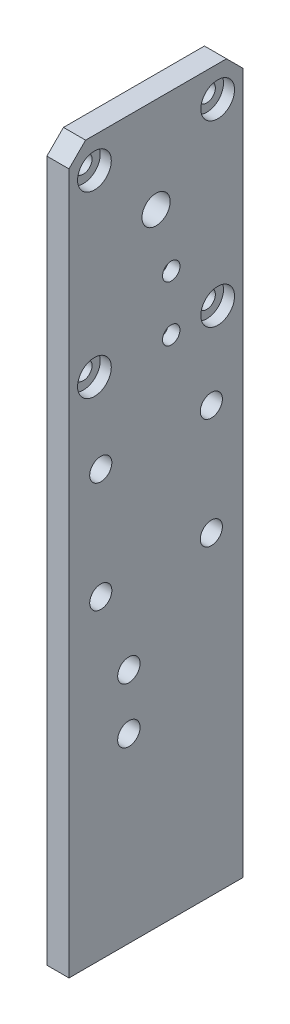
from build123d import *

# Parameters (mm, degrees)
CROQUIS1_W              = 31.5
CROQUIS1_H              = 126
SALIENTE_EXTRUIR1_DEPTH = 4
CROQUIS3_R              = 2
CORTAR_EXTRUIR2_DEPTH   = 5
CROQUIS8_R              = 2.55
CORTAR_EXTRUIR3_DEPTH   = 5
CROQUIS11_R             = 1.575
CORTAR_EXTRUIR8_DEPTH   = 5
CROQUIS15_R             = 1.575
CORTAR_EXTRUIR11_DEPTH  = 5
CHAFL_N2_SIZE           = 3
CROQUIS19_R             = 3.5
CORTAR_EXTRUIR13_DEPTH  = 1.9
CROQUIS20_R             = 3.05
CORTAR_EXTRUIR14_DEPTH  = 2
CROQUIS24_W             = 31.5
CROQUIS24_H             = 3.76
SALIENTE_EXTRUIR3_DEPTH = 4
CROQUIS25_R             = 2.025
CORTAR_EXTRUIR15_DEPTH  = 5


with BuildPart() as part:
    # Croquis1 → Saliente-Extruir1 (new body)
    with BuildSketch(Plane(origin=(0, 0, 0), x_dir=(0, 0, -1), z_dir=(1, 0, 0))):
        Rectangle(CROQUIS1_W, CROQUIS1_H)
    extrude(amount=SALIENTE_EXTRUIR1_DEPTH)

    # Croquis3 → Cortar-Extruir2 (cut, through all)
    with BuildSketch(Plane(origin=(4, 0, 0), x_dir=(0, 0, -1), z_dir=(1, 0, 0))):
        with Locations((-10, 10.1)):
            Circle(CROQUIS3_R)
        with Locations((10, 10.1)):
            Circle(CROQUIS3_R)
        with Locations((-10, -9.9)):
            Circle(CROQUIS3_R)
        with Locations((10, -9.9)):
            Circle(CROQUIS3_R)
    extrude(amount=-CORTAR_EXTRUIR2_DEPTH, mode=Mode.SUBTRACT)

    # Croquis8 → Cortar-Extruir3 (cut, through all)
    with BuildSketch(Plane.ZY):
        with Locations((0, 45.75)):
            Circle(CROQUIS8_R)
    extrude(amount=-CORTAR_EXTRUIR3_DEPTH, mode=Mode.SUBTRACT)

    # Croquis11 → Cortar-Extruir8 (cut, through all)
    with BuildSketch(Plane(origin=(4, 0, 0), x_dir=(0, 0, -1), z_dir=(1, 0, 0))):
        with Locations((2.75, 34.75)):
            Circle(CROQUIS11_R)
        with Locations((2.75, 24.75)):
            Circle(CROQUIS11_R)
    extrude(amount=-CORTAR_EXTRUIR8_DEPTH, mode=Mode.SUBTRACT)

    # Croquis15 → Cortar-Extruir11 (cut, through all)
    with BuildSketch(Plane(origin=(4, 0, 0), x_dir=(0, 0, -1), z_dir=(1, 0, 0))):
        with Locations((-11.15, 57.45)):
            Circle(CROQUIS15_R)
        with Locations((11.15, 57.45)):
            Circle(CROQUIS15_R)
        with Locations((-11.15, 25.1)):
            Circle(CROQUIS15_R)
        with Locations((11.15, 25.1)):
            Circle(CROQUIS15_R)
    extrude(amount=-CORTAR_EXTRUIR11_DEPTH, mode=Mode.SUBTRACT)

    # Chaflán2
    chafl_n2_edges = [part.edges().sort_by_distance(p)[0] for p in [
        (2, 63, 15.75),
        (2, 63, -15.75),
    ]]
    chamfer(chafl_n2_edges, length=CHAFL_N2_SIZE)

    # Croquis19 → Cortar-Extruir13 (cut)
    with BuildSketch(Plane.ZY):
        with Locations((-2.75, 24.75)):
            Circle(CROQUIS19_R)
        with Locations((-2.75, 34.75)):
            Circle(CROQUIS19_R)
    extrude(amount=-CORTAR_EXTRUIR13_DEPTH, mode=Mode.SUBTRACT)

    # Croquis20 → Cortar-Extruir14 (cut)
    with BuildSketch(Plane(origin=(4, 0, 0), x_dir=(0, 0, -1), z_dir=(1, 0, 0))):
        with Locations((-11.15, 57.45)):
            Circle(CROQUIS20_R)
        with Locations((11.15, 57.45)):
            Circle(CROQUIS20_R)
        with Locations((11.15, 25.1)):
            Circle(CROQUIS20_R)
        with Locations((-11.15, 25.1)):
            Circle(CROQUIS20_R)
    extrude(amount=-CORTAR_EXTRUIR14_DEPTH, mode=Mode.SUBTRACT)

    # Croquis24 → Saliente-Extruir3 (add)
    with BuildSketch(Plane(origin=(4, 0, 0), x_dir=(0, 0, -1), z_dir=(1, 0, 0))):
        with Locations((0, -64.88)):
            Rectangle(CROQUIS24_W, CROQUIS24_H)
    extrude(amount=-SALIENTE_EXTRUIR3_DEPTH)

    # Croquis25 → Cortar-Extruir15 (cut, through all)
    with BuildSketch(Plane(origin=(4, 0, 0), x_dir=(0, 0, -1), z_dir=(1, 0, 0))):
        with Locations((-4.91726189, -23.891280092)):
            Circle(CROQUIS25_R)
        with Locations((-4.91726189, -33.891280092)):
            Circle(CROQUIS25_R)
    extrude(amount=-CORTAR_EXTRUIR15_DEPTH, mode=Mode.SUBTRACT)


solid = part.part
